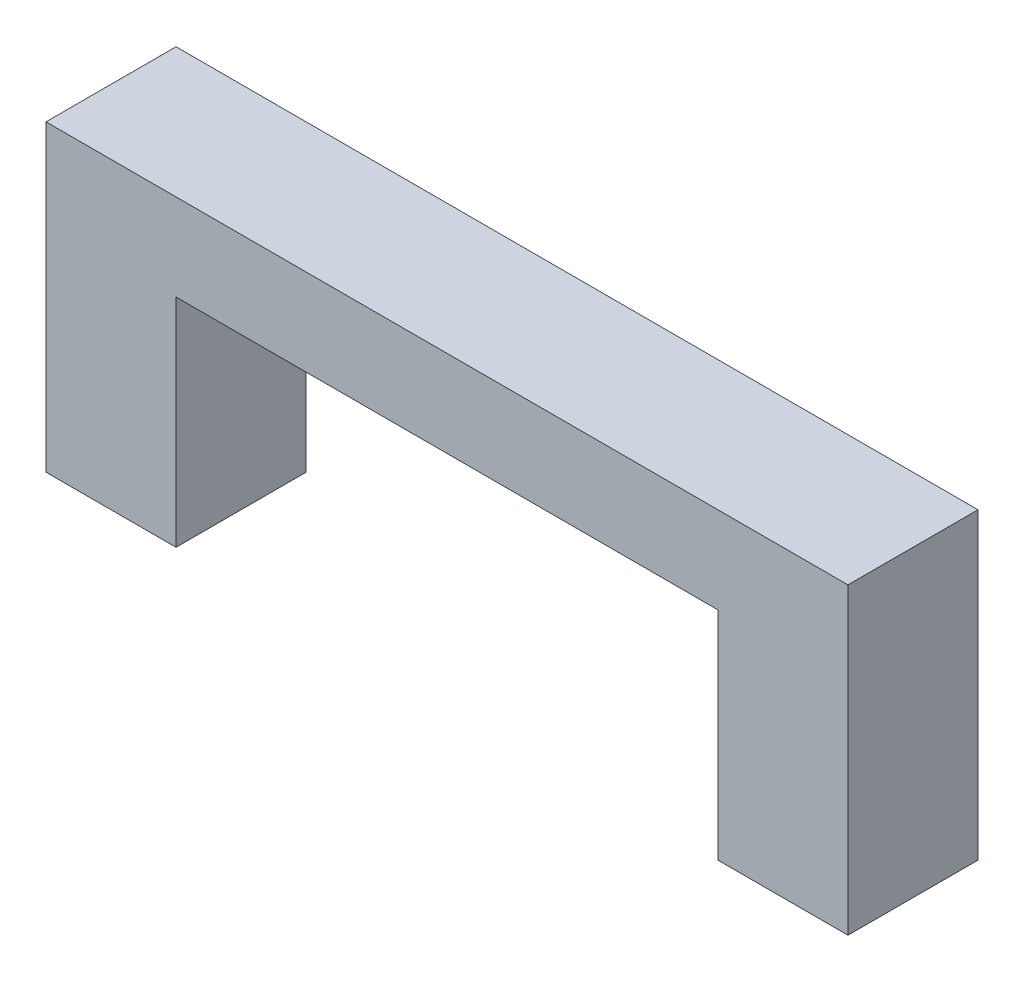
from build123d import *

# Parameters (mm, degrees)
BOSS_EXTRUDE1_DEPTH = 3
SKETCH2_W           = 1.5
SKETCH2_H           = 1.5
CUT_EXTRUDE1_DEPTH  = 2


with BuildPart() as part:
    # Sketch1 → Boss-Extrude1 (new body)
    with BuildSketch(Plane.XY):
        Polygon((0, 0), (0, 7), (18.5, 7), (18.5, 0), (15.5, 0), (15.5, 5), (3, 5), (3, 0), align=None)
    extrude(amount=BOSS_EXTRUDE1_DEPTH)

    # Sketch2 → Cut-Extrude1 (cut)
    with BuildSketch(Plane.XZ):
        with Locations((17, 1.5)):
            Rectangle(SKETCH2_W, SKETCH2_H)
        with Locations((1.5, 1.5)):
            Rectangle(SKETCH2_W, SKETCH2_H)
    extrude(amount=-CUT_EXTRUDE1_DEPTH, mode=Mode.SUBTRACT)


solid = part.part
